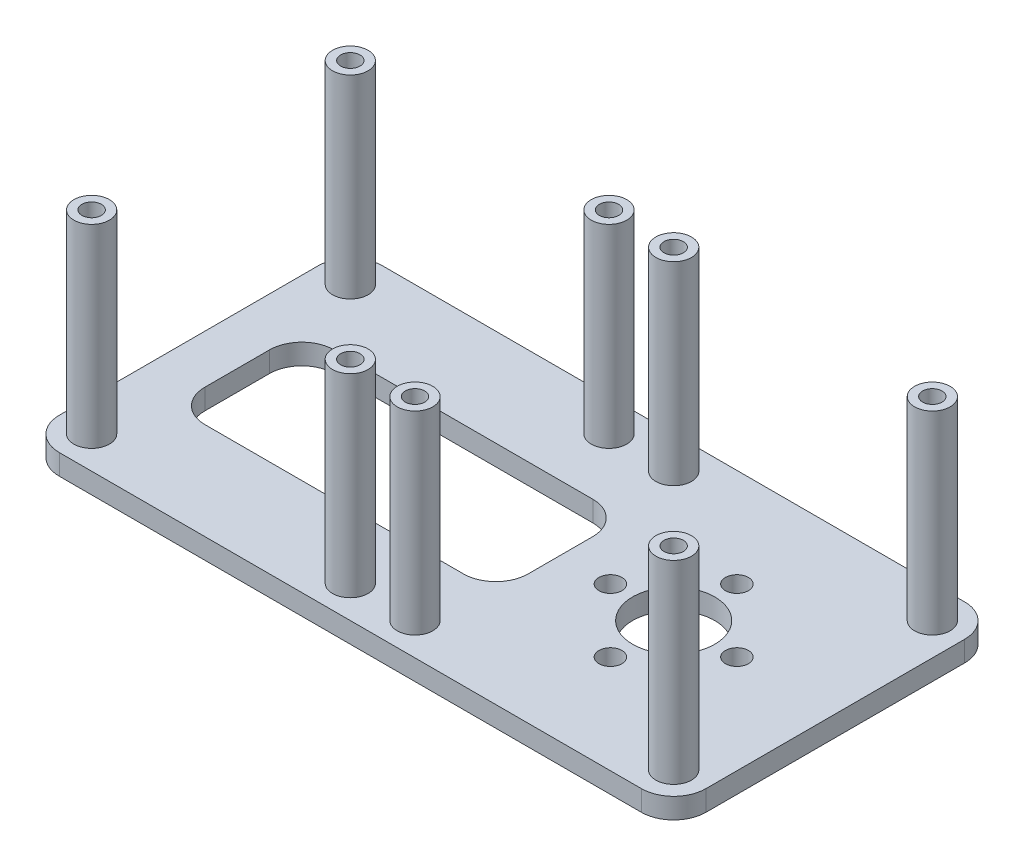
from build123d import *

# Parameters (mm, degrees)
SKETCH1_W           = 50
SKETCH1_H           = 50
SKETCH1_R           = 6.35
SKETCH1_R_2         = 1.778
BOSS_EXTRUDE1_DEPTH = 3.175
SKETCH2_R           = 2.75
SKETCH2_R_2         = 1.5
BOSS_EXTRUDE2_DEPTH = 30
SKETCH3_W           = 50
SKETCH3_H           = 50
BOSS_EXTRUDE3_DEPTH = 3.175
SKETCH4_R           = 2.75
SKETCH4_R_2         = 1.5
BOSS_EXTRUDE4_DEPTH = 30
SKETCH5_W           = 50
SKETCH5_H           = 20
CUT_EXTRUDE1_DEPTH  = 10
FILLET1_R           = 5


with BuildPart() as part:
    # Sketch1 → Boss-Extrude1 (new body)
    with BuildSketch(Plane(origin=(0, 0, 0), x_dir=(1, 0, 0), z_dir=(0, 1, 0))):
        Rectangle(SKETCH1_W, SKETCH1_H)
        Circle(SKETCH1_R, mode=Mode.SUBTRACT)
        with Locations((-9.779, 0)):
            Circle(SKETCH1_R_2, mode=Mode.SUBTRACT)
        with Locations((9.779, 0)):
            Circle(SKETCH1_R_2, mode=Mode.SUBTRACT)
        with Locations((0, 9.779)):
            Circle(SKETCH1_R_2, mode=Mode.SUBTRACT)
        with Locations((0, -9.779)):
            Circle(SKETCH1_R_2, mode=Mode.SUBTRACT)
    extrude(amount=BOSS_EXTRUDE1_DEPTH)

    # Sketch2 → Boss-Extrude2 (add)
    with BuildSketch(Plane(origin=(0, 3.175, 0), x_dir=(1, 0, 0), z_dir=(0, 1, 0))):
        with Locations((20, -20)):
            Circle(SKETCH2_R)
        with Locations((20, -20)):
            Circle(SKETCH2_R_2, mode=Mode.SUBTRACT)
        with Locations((-20, -20)):
            Circle(SKETCH2_R)
        with Locations((-20, -20)):
            Circle(SKETCH2_R_2, mode=Mode.SUBTRACT)
        with Locations((-20, 20)):
            Circle(SKETCH2_R)
        with Locations((-20, 20)):
            Circle(SKETCH2_R_2, mode=Mode.SUBTRACT)
        with Locations((20, 20)):
            Circle(SKETCH2_R)
        with Locations((20, 20)):
            Circle(SKETCH2_R_2, mode=Mode.SUBTRACT)
    extrude(amount=BOSS_EXTRUDE2_DEPTH)

    # Sketch3 → Boss-Extrude3 (add)
    with BuildSketch(Plane(origin=(0, 0, 0), x_dir=(1, 0, 0), z_dir=(0, 1, 0))):
        with Locations((-50, 0)):
            Rectangle(SKETCH3_W, SKETCH3_H)
    extrude(amount=BOSS_EXTRUDE3_DEPTH)

    # Sketch4 → Boss-Extrude4 (add)
    with BuildSketch(Plane(origin=(0, 3.175, 0), x_dir=(1, 0, 0), z_dir=(0, 1, 0))):
        with Locations((-70, 20)):
            Circle(SKETCH4_R)
        with Locations((-70, 20)):
            Circle(SKETCH4_R_2, mode=Mode.SUBTRACT)
        with Locations((-70, -20)):
            Circle(SKETCH4_R)
        with Locations((-70, -20)):
            Circle(SKETCH4_R_2, mode=Mode.SUBTRACT)
        with Locations((-30, -20)):
            Circle(SKETCH4_R)
        with Locations((-30, -20)):
            Circle(SKETCH4_R_2, mode=Mode.SUBTRACT)
        with Locations((-30, 20)):
            Circle(SKETCH4_R)
        with Locations((-30, 20)):
            Circle(SKETCH4_R_2, mode=Mode.SUBTRACT)
    extrude(amount=BOSS_EXTRUDE4_DEPTH)

    # Sketch5 → Cut-Extrude1 (cut)
    with BuildSketch(Plane(origin=(0, 3.175, 0), x_dir=(1, 0, 0), z_dir=(0, 1, 0))):
        with Locations((-42.5, 0)):
            Rectangle(SKETCH5_W, SKETCH5_H)
    extrude(amount=-CUT_EXTRUDE1_DEPTH, mode=Mode.SUBTRACT)

    # Fillet1
    fillet1_edges = [part.edges().sort_by_distance(p)[0] for p in [
        (-67.5, 1.5875, 10),
        (-67.5, 1.5875, -10),
        (-17.5, 1.5875, -10),
        (-17.5, 1.5875, 10),
        (-75, 1.5875, 25),
        (-75, 1.5875, -25),
        (25, 1.5875, 25),
        (25, 1.5875, -25),
    ]]
    fillet(fillet1_edges, radius=FILLET1_R)


solid = part.part
